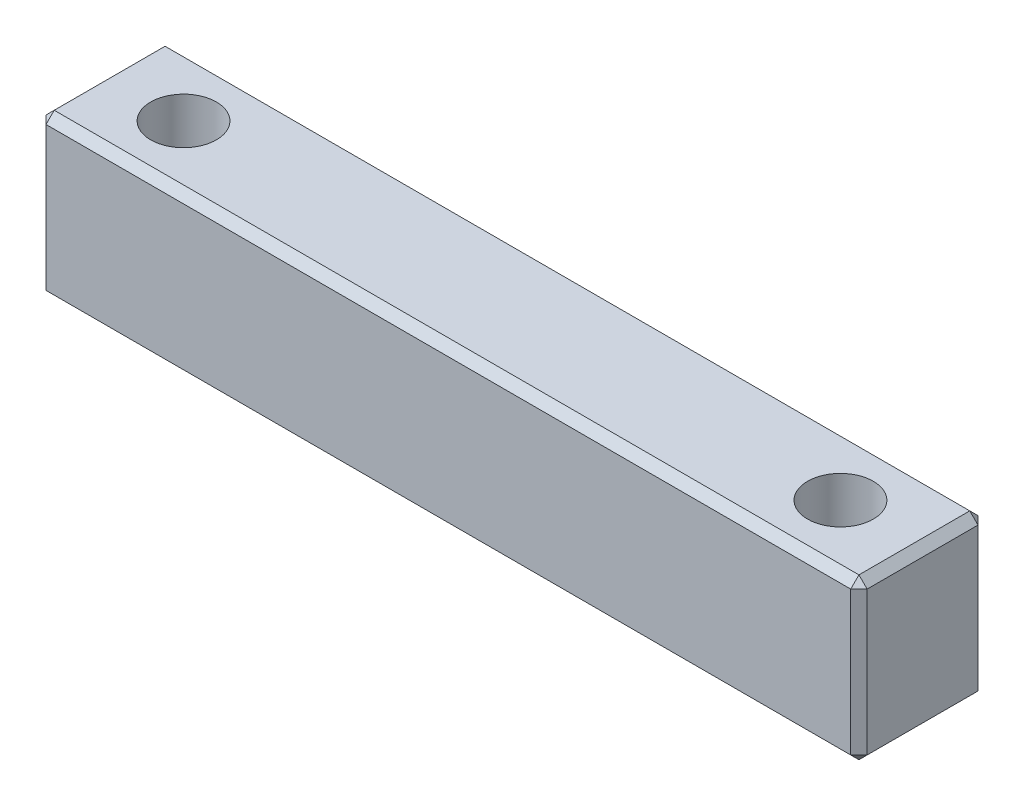
from build123d import *

# Parameters (mm, degrees)
SKETCH1_W           = 7.75
SKETCH1_H           = 9.75
BOSS_EXTRUDE1_DEPTH = 50
SKETCH4_R           = 2
CUT_EXTRUDE3_DEPTH  = 9.75
CHAMFER1_SIZE       = 0.5


with BuildPart() as part:
    # Sketch1 → Boss-Extrude1 (new body)
    with BuildSketch(Plane(origin=(0, 0, 0), x_dir=(0, 0, -1), z_dir=(1, 0, 0))):
        with Locations((3.875, 4.875)):
            Rectangle(SKETCH1_W, SKETCH1_H)
    extrude(amount=BOSS_EXTRUDE1_DEPTH)

    # Sketch4 → Cut-Extrude3 (cut)
    with BuildSketch(Plane(origin=(0, 9.75, 0), x_dir=(1, 0, 0), z_dir=(0, 1, 0))):
        with Locations((5, 3.875)):
            Circle(SKETCH4_R)
        with Locations((45, 3.875)):
            Circle(SKETCH4_R)
    extrude(amount=-CUT_EXTRUDE3_DEPTH, mode=Mode.SUBTRACT)

    # Chamfer1
    chamfer1_edges = [part.edges().sort_by_distance(p)[0] for p in [
        (50, 4.875, -7.75),
        (50, 9.75, -3.875),
        (50, 4.875, 0),
        (0, 9.75, -3.875),
        (0, 4.875, -7.75),
        (0, 0, -3.875),
        (0, 4.875, 0),
        (25, 9.75, 0),
        (25, 9.75, -7.75),
        (25, 0, -7.75),
        (25, 0, 0),
        (50, 0, -3.875),
    ]]
    chamfer(chamfer1_edges, length=CHAMFER1_SIZE)


solid = part.part
